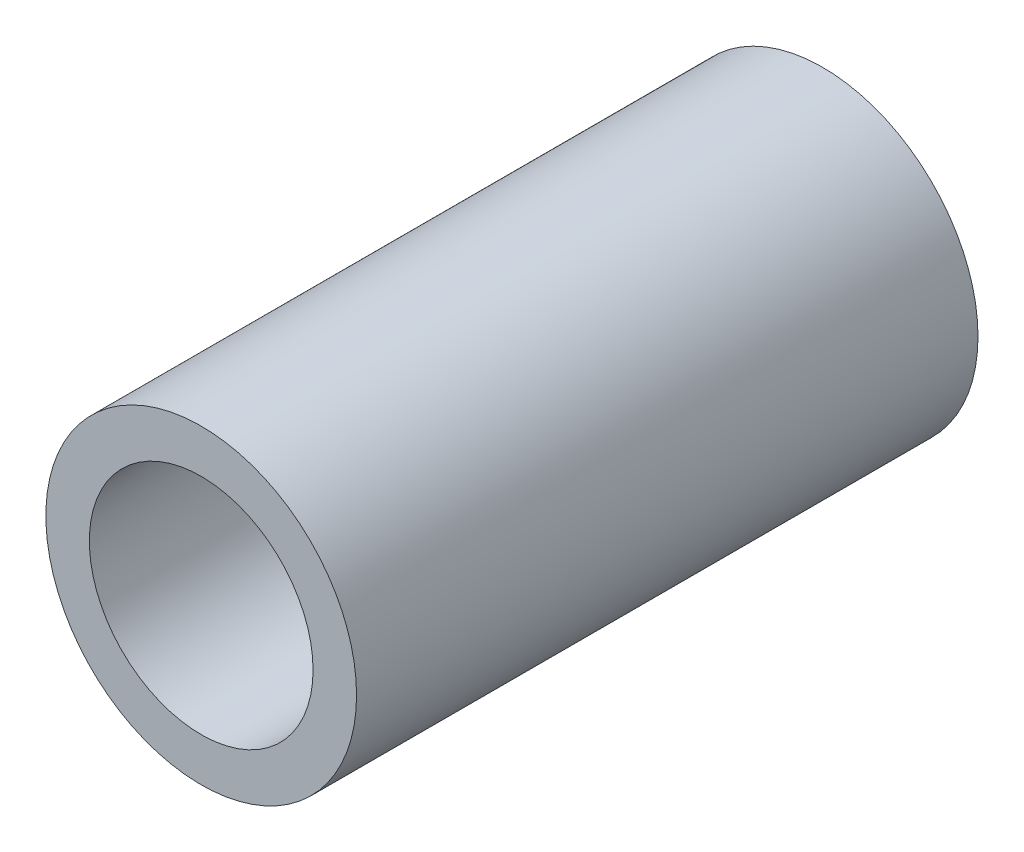
from build123d import *

# Parameters (mm, degrees)
SKETCH1_R           = 1.5875
SKETCH1_R_2         = 1.143
EXTRUDE1_DEPTH      = 3.175
EXTRUDE1_DEPTH_BACK = 3.175


with BuildPart() as part:
    # Sketch1 → Extrude1 (new body, two sides)
    with BuildSketch(Plane.XY) as extrude1_sk:
        Circle(SKETCH1_R)
        Circle(SKETCH1_R_2, mode=Mode.SUBTRACT)
    extrude(amount=EXTRUDE1_DEPTH)
    extrude(extrude1_sk.sketch, amount=-EXTRUDE1_DEPTH_BACK)


solid = part.part
